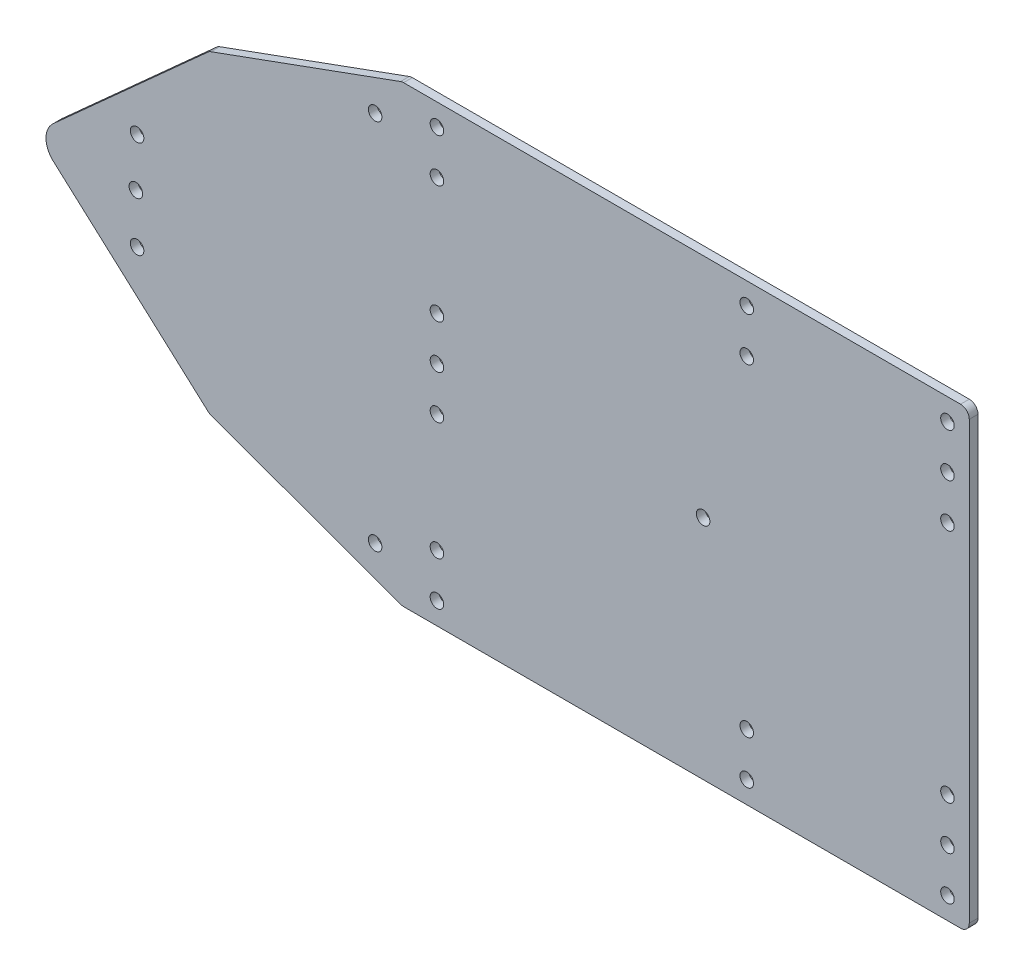
from build123d import *

# Parameters (mm, degrees)
EXTRUDE_1_DEPTH     = 2
FILLET_1_R          = 5
FILLET_2_R          = 2
SKETCH_2_R          = 1.55
CUT_EXTRUDE_1_DEPTH = 2


with BuildPart() as part:
    # 草图1 → 凸台-拉伸1 (new body)
    with BuildSketch(Plane.XY):
        Polygon((387.201278127, -62.835808376), (387.201278127, 41.164191624), (257.201278127, 41.164191624), (213.03572495, 25.089244888), (173.136911199, -10.835808376), (213.03572495, -46.760861639), (257.201278127, -62.835808376), align=None)
    extrude(amount=EXTRUDE_1_DEPTH)

    # 圆角1
    fillet_1_edges = [part.edges().sort_by_distance(p)[0] for p in [
        (173.136911199, -10.835808376, 1),
    ]]
    fillet(fillet_1_edges, radius=FILLET_1_R)

    # 圆角2
    fillet_2_edges = [part.edges().sort_by_distance(p)[0] for p in [
        (257.201278127, -62.835808376, 1),
        (213.03572495, -46.760861639, 1),
        (213.03572495, 25.089244888, 1),
        (257.201278127, 41.164191624, 1),
        (387.201278127, 41.164191624, 1),
        (387.201278127, -62.835808376, 1),
    ]]
    fillet(fillet_2_edges, radius=FILLET_2_R)

    # 草图2 → 切除-拉伸1 (cut)
    with BuildSketch(Plane(origin=(0, 0, 0), x_dir=(-1, 0, 0), z_dir=(0, 0, -1))):
        with Locations((-265.201278127, 36.164191624)):
            Circle(SKETCH_2_R)
        with Locations((-251.041024089, 31.834064606)):
            Circle(SKETCH_2_R)
        with Locations((-336.201278127, 26.164191624)):
            Circle(SKETCH_2_R)
        with Locations((-265.201278127, 26.164191624)):
            Circle(SKETCH_2_R)
        with Locations((-265.201278127, -0.835808376)):
            Circle(SKETCH_2_R)
        with Locations((-382.201278127, 36.164191624)):
            Circle(SKETCH_2_R)
        with Locations((-382.201278127, 26.164191624)):
            Circle(SKETCH_2_R)
        with Locations((-196.481423651, 0.334064606)):
            Circle(SKETCH_2_R)
        with Locations((-326.201278127, -10.835808376)):
            Circle(SKETCH_2_R)
        with Locations((-196.201278127, -10.835808376)):
            Circle(SKETCH_2_R)
        with Locations((-196.481423651, -22.005681357)):
            Circle(SKETCH_2_R)
        with Locations((-265.201278127, -20.835808376)):
            Circle(SKETCH_2_R)
        with Locations((-265.201278127, -57.835808376)):
            Circle(SKETCH_2_R)
        with Locations((-265.201278127, -47.835808376)):
            Circle(SKETCH_2_R)
        with Locations((-336.201278127, -47.835808376)):
            Circle(SKETCH_2_R)
        with Locations((-382.201278127, -47.835808376)):
            Circle(SKETCH_2_R)
        with Locations((-382.201278127, -57.835808376)):
            Circle(SKETCH_2_R)
        with Locations((-265.201278127, -10.835808376)):
            Circle(SKETCH_2_R)
        with Locations((-336.201278127, 36.164191624)):
            Circle(SKETCH_2_R)
        with Locations((-336.201278127, -57.835808376)):
            Circle(SKETCH_2_R)
        with Locations((-251.041024089, -53.505681357)):
            Circle(SKETCH_2_R)
        with Locations((-382.201278127, 16.164191624)):
            Circle(SKETCH_2_R)
        with Locations((-382.201278127, -37.835808376)):
            Circle(SKETCH_2_R)
    extrude(amount=-CUT_EXTRUDE_1_DEPTH, mode=Mode.SUBTRACT)


solid = part.part
